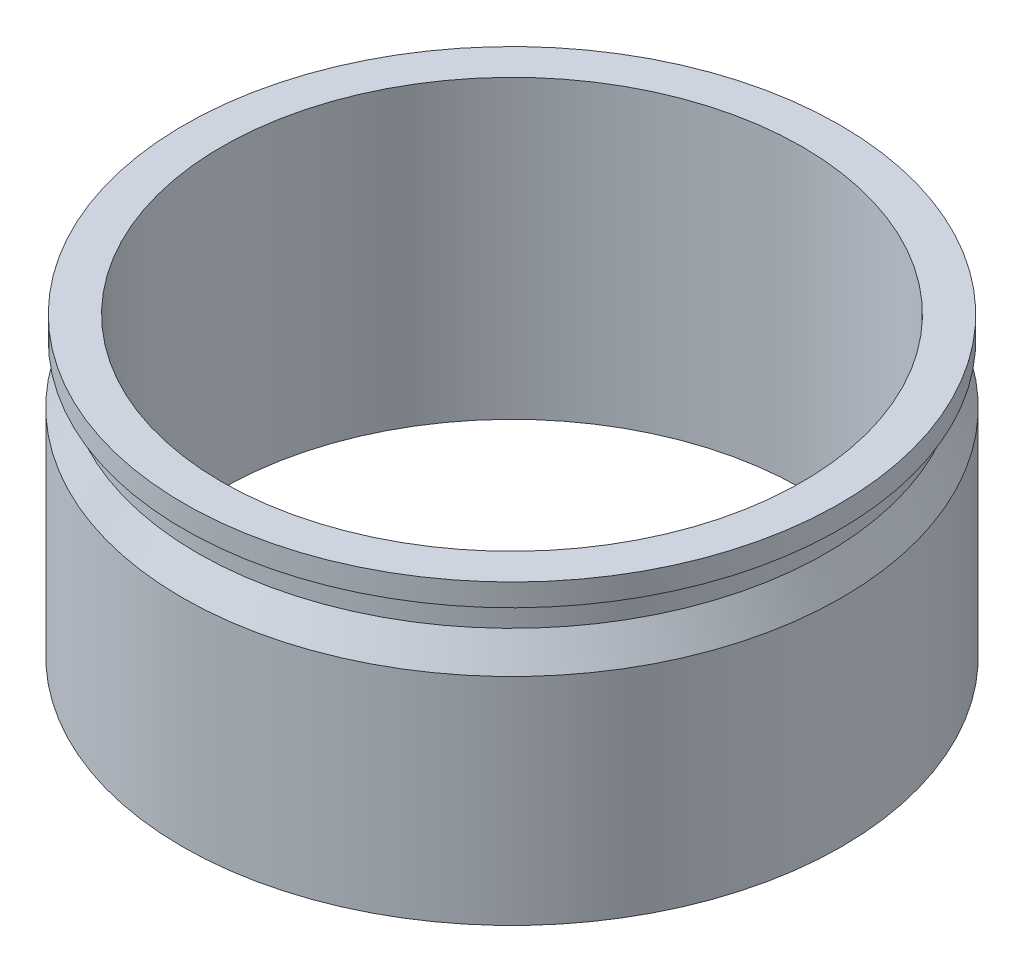
from build123d import *


with BuildPart() as part:
    # Sketch2 one side → Revolve-Thin1 (revolve)
    with BuildSketch(Plane.XY, mode=Mode.PRIVATE) as revolve_thin1_sk:
        Polygon((-325.5, 1707.83763204), (-325.5, 2040), (-367.75, 2040), (-367.75, 2015), (-352.5, 2015), (-352.5, 1984.235457461), (-369.75, 1949.635457461), (-369.75, 1707.83763204), align=None)
        Polygon((-366.75, 2039), (-326.5, 2039), (-326.5, 1708.83763204), (-368.75, 1708.83763204), (-368.75, 1949.4), (-351.5, 1984), (-351.5, 2016), (-366.75, 2016), align=None, mode=Mode.SUBTRACT)
    revolve(revolve_thin1_sk.sketch.rotate(Axis((0, 1764, 0), (0, 1, 0)), 270), axis=Axis((0, 1764, 0), (0, 1, 0)))  # turned: the seam where the file's is


solid = part.part
